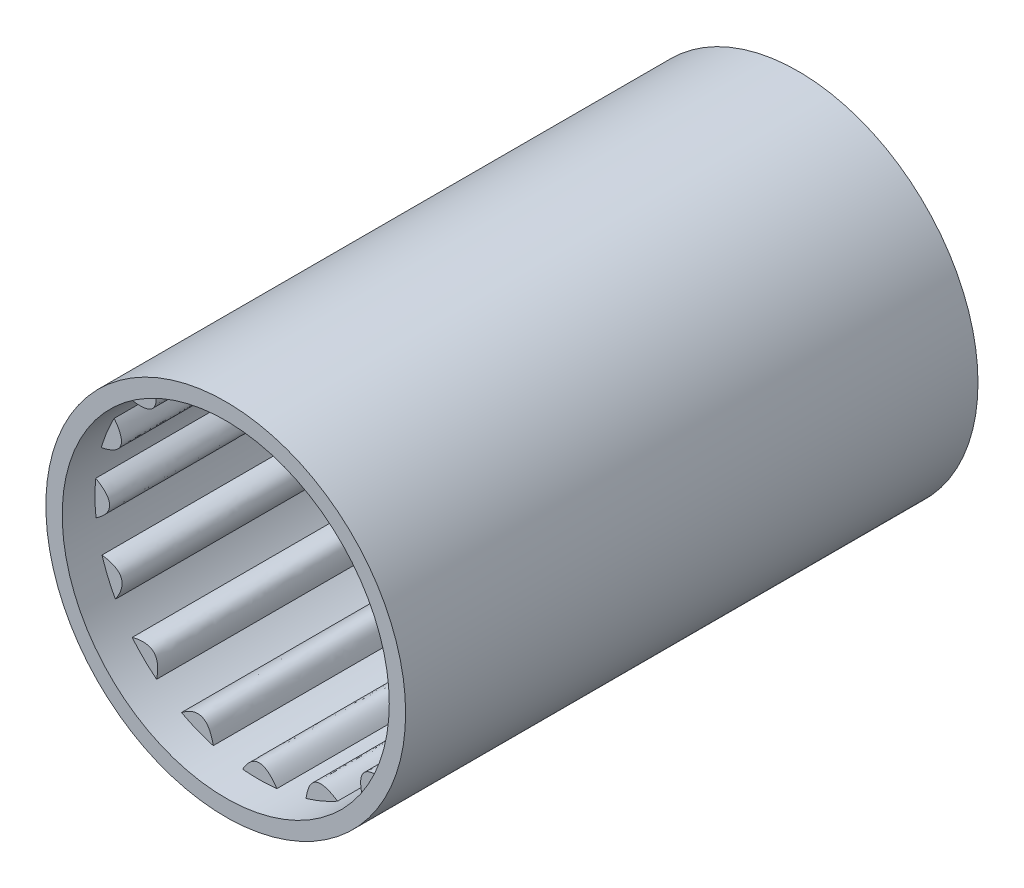
from build123d import *

# Parameters (mm, degrees)
SKETCH1_R              = 11
SKETCH1_R_2            = 10
BOSS_EXTRUDE1_DEPTH    = 35
BOSS_EXTRUDE2_DEPTH    = 33
BOSS_EXTRUDE2_2_DEPTH  = 33
BOSS_EXTRUDE2_3_DEPTH  = 33
BOSS_EXTRUDE2_4_DEPTH  = 33
BOSS_EXTRUDE2_5_DEPTH  = 33
BOSS_EXTRUDE2_6_DEPTH  = 33
BOSS_EXTRUDE2_7_DEPTH  = 33
BOSS_EXTRUDE2_8_DEPTH  = 33
BOSS_EXTRUDE2_9_DEPTH  = 33
BOSS_EXTRUDE2_10_DEPTH = 33
BOSS_EXTRUDE2_11_DEPTH = 33
BOSS_EXTRUDE2_12_DEPTH = 33
BOSS_EXTRUDE2_13_DEPTH = 33
BOSS_EXTRUDE2_14_DEPTH = 33
BOSS_EXTRUDE2_15_DEPTH = 33
BOSS_EXTRUDE2_16_DEPTH = 33


with BuildPart() as part:
    # Sketch1 → Boss-Extrude1 (new body)
    with BuildSketch(Plane.XY):
        Circle(SKETCH1_R)
        Circle(SKETCH1_R_2, mode=Mode.SUBTRACT)
    extrude(amount=BOSS_EXTRUDE1_DEPTH)


with BuildPart() as body_2:
    # Sketch2 → Boss-Extrude2 (new body)
    with BuildSketch(Plane(origin=(0, 0, 0), x_dir=(-1, 0, 0), z_dir=(0, 0, -1))):
        with BuildLine():
            add(Edge.make_bspline(
                [(-1.128056704, -9.936170695), (-0.00880064, -8.26174576), (0.975113037, -9.952344174)],
                knots=[0, 0, 0, 1, 1, 1], degree=2))
            add(Edge.make_bspline(
                [(-1.128056704, -9.936170695), (-0.076898223, -10.055152863), (0.975113037, -9.952344174)],
                knots=[0, 0, 0, 1, 1, 1], degree=2))
        make_face()
    extrude(amount=-BOSS_EXTRUDE2_DEPTH)


with BuildPart() as body_3:
    # Sketch2 → Boss-Extrude2 2 (new body)
    with BuildSketch(Plane(origin=(0, 0, 0), x_dir=(-1, 0, 0), z_dir=(0, 0, -1))):
        with BuildLine():
            add(Edge.make_bspline(
                [(-4.844596406, -8.748136125), (-3.169763956, -7.629489952), (-2.907710252, -9.567926687)],
                knots=[0, 0, 0, 1, 1, 1], degree=2))
            add(Edge.make_bspline(
                [(-4.844596406, -8.748136125), (-3.918985104, -9.26032225), (-2.907710252, -9.567926687)],
                knots=[0, 0, 0, 1, 1, 1], degree=2))
        make_face()
    extrude(amount=-BOSS_EXTRUDE2_2_DEPTH)


with BuildPart() as body_4:
    # Sketch2 → Boss-Extrude2 3 (new body)
    with BuildSketch(Plane(origin=(0, 0, 0), x_dir=(-1, 0, 0), z_dir=(0, 0, -1))):
        with BuildLine():
            add(Edge.make_bspline(
                [(-7.823590222, -6.228277132), (-5.848159444, -5.835713459), (-6.347861013, -7.726879095)],
                knots=[0, 0, 0, 1, 1, 1], degree=2))
            add(Edge.make_bspline(
                [(-7.823590222, -6.228277132), (-7.16444203, -7.05569152), (-6.347861013, -7.726879095)],
                knots=[0, 0, 0, 1, 1, 1], degree=2))
        make_face()
    extrude(amount=-BOSS_EXTRUDE2_3_DEPTH)


with BuildPart() as body_5:
    # Sketch2 → Boss-Extrude2 4 (new body)
    with BuildSketch(Plane(origin=(0, 0, 0), x_dir=(-1, 0, 0), z_dir=(0, 0, -1))):
        with BuildLine():
            add(Edge.make_bspline(
                [(-9.611513348, -2.760219406), (-7.63622567, -3.153502494), (-8.821607479, -4.709484206)],
                knots=[0, 0, 0, 1, 1, 1], degree=2))
            add(Edge.make_bspline(
                [(-9.611513348, -2.760219406), (-9.319177602, -3.776895716), (-8.821607479, -4.709484206)],
                knots=[0, 0, 0, 1, 1, 1], degree=2))
        make_face()
    extrude(amount=-BOSS_EXTRUDE2_4_DEPTH)


with BuildPart() as body_6:
    # Sketch2 → Boss-Extrude2 5 (new body)
    with BuildSketch(Plane(origin=(0, 0, 0), x_dir=(-1, 0, 0), z_dir=(0, 0, -1))):
        with BuildLine():
            add(Edge.make_bspline(
                [(-9.936170695, 1.128056704), (-8.26174576, 0.00880064), (-9.952344174, -0.975113037)],
                knots=[0, 0, 0, 1, 1, 1], degree=2))
            add(Edge.make_bspline(
                [(-9.936170695, 1.128056704), (-10.055152863, 0.076898223), (-9.952344174, -0.975113037)],
                knots=[0, 0, 0, 1, 1, 1], degree=2))
        make_face()
    extrude(amount=-BOSS_EXTRUDE2_5_DEPTH)


with BuildPart() as body_7:
    # Sketch2 → Boss-Extrude2 6 (new body)
    with BuildSketch(Plane(origin=(0, 0, 0), x_dir=(-1, 0, 0), z_dir=(0, 0, -1))):
        with BuildLine():
            add(Edge.make_bspline(
                [(-8.748136125, 4.844596406), (-7.629489952, 3.169763956), (-9.567926687, 2.907710252)],
                knots=[0, 0, 0, 1, 1, 1], degree=2))
            add(Edge.make_bspline(
                [(-8.748136125, 4.844596406), (-9.26032225, 3.918985104), (-9.567926687, 2.907710252)],
                knots=[0, 0, 0, 1, 1, 1], degree=2))
        make_face()
    extrude(amount=-BOSS_EXTRUDE2_6_DEPTH)


with BuildPart() as body_8:
    # Sketch2 → Boss-Extrude2 7 (new body)
    with BuildSketch(Plane(origin=(0, 0, 0), x_dir=(-1, 0, 0), z_dir=(0, 0, -1))):
        with BuildLine():
            add(Edge.make_bspline(
                [(-6.228277132, 7.823590222), (-5.835713459, 5.848159444), (-7.726879095, 6.347861013)],
                knots=[0, 0, 0, 1, 1, 1], degree=2))
            add(Edge.make_bspline(
                [(-6.228277132, 7.823590222), (-7.05569152, 7.16444203), (-7.726879095, 6.347861013)],
                knots=[0, 0, 0, 1, 1, 1], degree=2))
        make_face()
    extrude(amount=-BOSS_EXTRUDE2_7_DEPTH)


with BuildPart() as body_9:
    # Sketch2 → Boss-Extrude2 8 (new body)
    with BuildSketch(Plane(origin=(0, 0, 0), x_dir=(-1, 0, 0), z_dir=(0, 0, -1))):
        with BuildLine():
            add(Edge.make_bspline(
                [(-2.760219406, 9.611513348), (-3.153502494, 7.63622567), (-4.709484206, 8.821607479)],
                knots=[0, 0, 0, 1, 1, 1], degree=2))
            add(Edge.make_bspline(
                [(-2.760219406, 9.611513348), (-3.776895716, 9.319177602), (-4.709484206, 8.821607479)],
                knots=[0, 0, 0, 1, 1, 1], degree=2))
        make_face()
    extrude(amount=-BOSS_EXTRUDE2_8_DEPTH)


with BuildPart() as body_10:
    # Sketch2 → Boss-Extrude2 9 (new body)
    with BuildSketch(Plane(origin=(0, 0, 0), x_dir=(-1, 0, 0), z_dir=(0, 0, -1))):
        with BuildLine():
            add(Edge.make_bspline(
                [(1.128056704, 9.936170695), (0.00880064, 8.26174576), (-0.975113037, 9.952344174)],
                knots=[0, 0, 0, 1, 1, 1], degree=2))
            add(Edge.make_bspline(
                [(1.128056704, 9.936170695), (0.076898223, 10.055152863), (-0.975113037, 9.952344174)],
                knots=[0, 0, 0, 1, 1, 1], degree=2))
        make_face()
    extrude(amount=-BOSS_EXTRUDE2_9_DEPTH)


with BuildPart() as body_11:
    # Sketch2 → Boss-Extrude2 10 (new body)
    with BuildSketch(Plane(origin=(0, 0, 0), x_dir=(-1, 0, 0), z_dir=(0, 0, -1))):
        with BuildLine():
            add(Edge.make_bspline(
                [(4.844596406, 8.748136125), (3.169763956, 7.629489952), (2.907710252, 9.567926687)],
                knots=[0, 0, 0, 1, 1, 1], degree=2))
            add(Edge.make_bspline(
                [(4.844596406, 8.748136125), (3.918985104, 9.26032225), (2.907710252, 9.567926687)],
                knots=[0, 0, 0, 1, 1, 1], degree=2))
        make_face()
    extrude(amount=-BOSS_EXTRUDE2_10_DEPTH)


with BuildPart() as body_12:
    # Sketch2 → Boss-Extrude2 11 (new body)
    with BuildSketch(Plane(origin=(0, 0, 0), x_dir=(-1, 0, 0), z_dir=(0, 0, -1))):
        with BuildLine():
            add(Edge.make_bspline(
                [(7.823590222, 6.228277132), (5.848159444, 5.835713459), (6.347861013, 7.726879095)],
                knots=[0, 0, 0, 1, 1, 1], degree=2))
            add(Edge.make_bspline(
                [(7.823590222, 6.228277132), (7.16444203, 7.05569152), (6.347861013, 7.726879095)],
                knots=[0, 0, 0, 1, 1, 1], degree=2))
        make_face()
    extrude(amount=-BOSS_EXTRUDE2_11_DEPTH)


with BuildPart() as body_13:
    # Sketch2 → Boss-Extrude2 12 (new body)
    with BuildSketch(Plane(origin=(0, 0, 0), x_dir=(-1, 0, 0), z_dir=(0, 0, -1))):
        with BuildLine():
            add(Edge.make_bspline(
                [(9.611513348, 2.760219406), (7.63622567, 3.153502494), (8.821607479, 4.709484206)],
                knots=[0, 0, 0, 1, 1, 1], degree=2))
            add(Edge.make_bspline(
                [(9.611513348, 2.760219406), (9.319177602, 3.776895716), (8.821607479, 4.709484206)],
                knots=[0, 0, 0, 1, 1, 1], degree=2))
        make_face()
    extrude(amount=-BOSS_EXTRUDE2_12_DEPTH)


with BuildPart() as body_14:
    # Sketch2 → Boss-Extrude2 13 (new body)
    with BuildSketch(Plane(origin=(0, 0, 0), x_dir=(-1, 0, 0), z_dir=(0, 0, -1))):
        with BuildLine():
            add(Edge.make_bspline(
                [(9.936170695, -1.128056704), (8.26174576, -0.00880064), (9.952344174, 0.975113037)],
                knots=[0, 0, 0, 1, 1, 1], degree=2))
            add(Edge.make_bspline(
                [(9.936170695, -1.128056704), (10.055152863, -0.076898223), (9.952344174, 0.975113037)],
                knots=[0, 0, 0, 1, 1, 1], degree=2))
        make_face()
    extrude(amount=-BOSS_EXTRUDE2_13_DEPTH)


with BuildPart() as body_15:
    # Sketch2 → Boss-Extrude2 14 (new body)
    with BuildSketch(Plane(origin=(0, 0, 0), x_dir=(-1, 0, 0), z_dir=(0, 0, -1))):
        with BuildLine():
            add(Edge.make_bspline(
                [(8.748136125, -4.844596406), (7.629489952, -3.169763956), (9.567926687, -2.907710252)],
                knots=[0, 0, 0, 1, 1, 1], degree=2))
            add(Edge.make_bspline(
                [(8.748136125, -4.844596406), (9.26032225, -3.918985104), (9.567926687, -2.907710252)],
                knots=[0, 0, 0, 1, 1, 1], degree=2))
        make_face()
    extrude(amount=-BOSS_EXTRUDE2_14_DEPTH)


with BuildPart() as body_16:
    # Sketch2 → Boss-Extrude2 15 (new body)
    with BuildSketch(Plane(origin=(0, 0, 0), x_dir=(-1, 0, 0), z_dir=(0, 0, -1))):
        with BuildLine():
            add(Edge.make_bspline(
                [(6.228277132, -7.823590222), (5.835713459, -5.848159444), (7.726879095, -6.347861013)],
                knots=[0, 0, 0, 1, 1, 1], degree=2))
            add(Edge.make_bspline(
                [(6.228277132, -7.823590222), (7.05569152, -7.16444203), (7.726879095, -6.347861013)],
                knots=[0, 0, 0, 1, 1, 1], degree=2))
        make_face()
    extrude(amount=-BOSS_EXTRUDE2_15_DEPTH)


with BuildPart() as body_17:
    # Sketch2 → Boss-Extrude2 16 (new body)
    with BuildSketch(Plane(origin=(0, 0, 0), x_dir=(-1, 0, 0), z_dir=(0, 0, -1))):
        with BuildLine():
            add(Edge.make_bspline(
                [(2.760219406, -9.611513348), (3.153502494, -7.63622567), (4.709484206, -8.821607479)],
                knots=[0, 0, 0, 1, 1, 1], degree=2))
            add(Edge.make_bspline(
                [(2.760219406, -9.611513348), (3.776895716, -9.319177602), (4.709484206, -8.821607479)],
                knots=[0, 0, 0, 1, 1, 1], degree=2))
        make_face()
    extrude(amount=-BOSS_EXTRUDE2_16_DEPTH)


solid = Compound([part.part, body_2.part, body_3.part, body_4.part, body_5.part, body_6.part, body_7.part, body_8.part, body_9.part, body_10.part, body_11.part, body_12.part, body_13.part, body_14.part, body_15.part, body_16.part, body_17.part])
